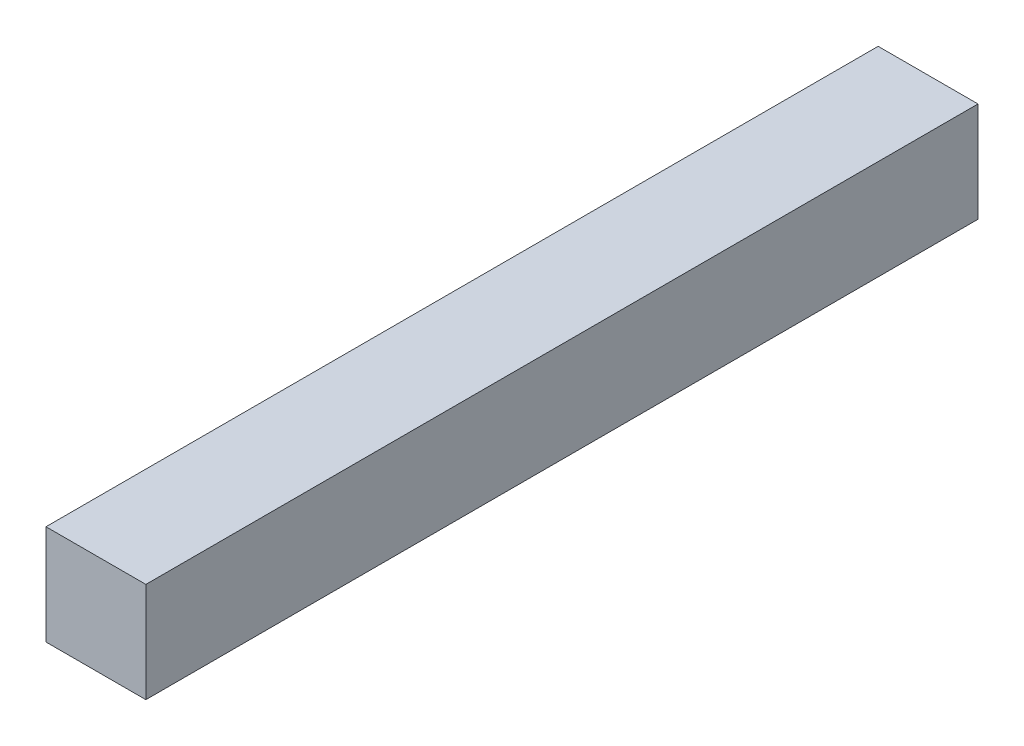
from build123d import *

# Parameters (mm, degrees)
SCHIZZO1_W                   = 3
SCHIZZO1_H                   = 3
ESTRUSIONE_ESTRUSIONE1_DEPTH = 25


with BuildPart() as part:
    # Schizzo1 → Estrusione-Estrusione1 (new body)
    with BuildSketch(Plane.XY):
        with Locations((1.5, -1.5)):
            Rectangle(SCHIZZO1_W, SCHIZZO1_H)
    extrude(amount=ESTRUSIONE_ESTRUSIONE1_DEPTH)


solid = part.part
